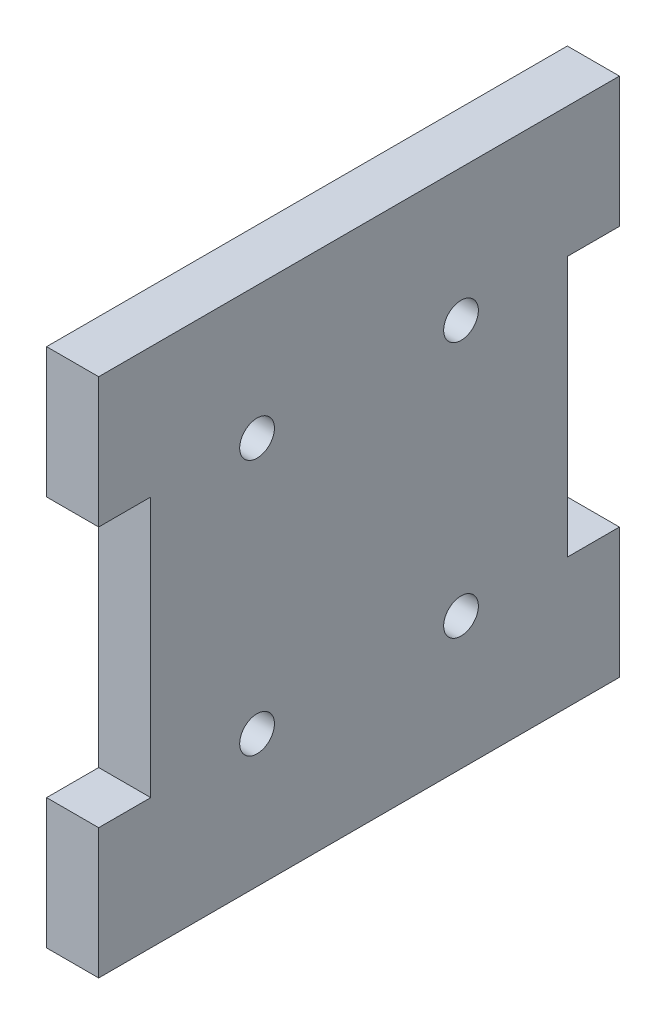
from build123d import *

# Parameters (mm, degrees)
SKETCH1_W           = 60
SKETCH1_H           = 60
BOSS_EXTRUDE1_DEPTH = 6
SKETCH2_W           = 6
SKETCH2_H           = 30
CUT_EXTRUDE1_DEPTH  = 6
SKETCH3_R           = 2
CUT_EXTRUDE2_DEPTH  = 6


with BuildPart() as part:
    # Sketch1 → Boss-Extrude1 (new body)
    with BuildSketch(Plane(origin=(0, 0, 0), x_dir=(0, 0, -1), z_dir=(1, 0, 0))):
        with Locations((30, -30)):
            Rectangle(SKETCH1_W, SKETCH1_H)
    extrude(amount=BOSS_EXTRUDE1_DEPTH)

    # Sketch2 → Cut-Extrude1 (cut)
    with BuildSketch(Plane(origin=(6, 0, 0), x_dir=(0, 0, -1), z_dir=(1, 0, 0))):
        with Locations((3, -30)):
            Rectangle(SKETCH2_W, SKETCH2_H)
        with Locations((57, -30)):
            Rectangle(SKETCH2_W, SKETCH2_H)
    extrude(amount=-CUT_EXTRUDE1_DEPTH, mode=Mode.SUBTRACT)

    # Sketch3 → Cut-Extrude2 (cut)
    with BuildSketch(Plane(origin=(6, 0, 0), x_dir=(0, 0, -1), z_dir=(1, 0, 0))):
        with Locations((18.25, -15.25)):
            Circle(SKETCH3_R)
        with Locations((41.75, -15.25)):
            Circle(SKETCH3_R)
        with Locations((41.75, -44.75)):
            Circle(SKETCH3_R)
        with Locations((18.25, -44.75)):
            Circle(SKETCH3_R)
    extrude(amount=-CUT_EXTRUDE2_DEPTH, mode=Mode.SUBTRACT)


solid = part.part
